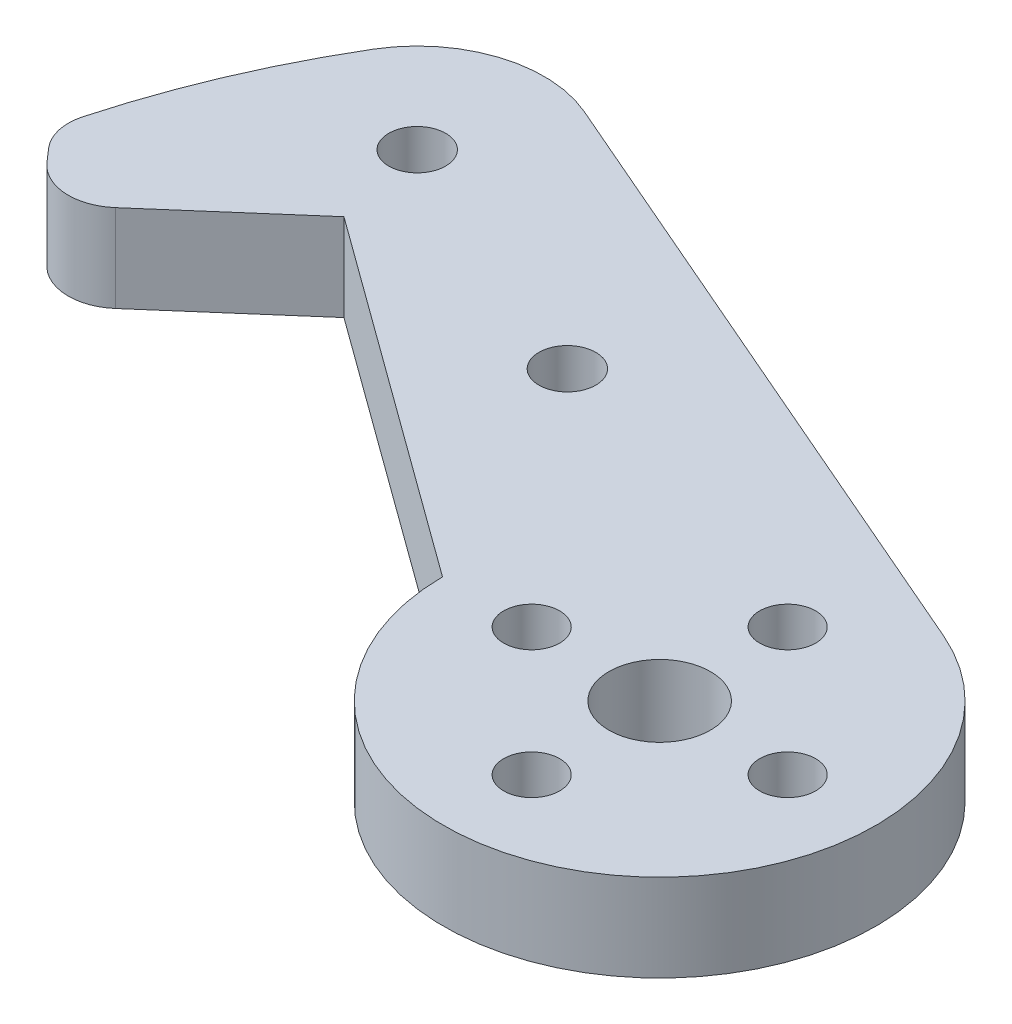
from build123d import *

# Parameters (mm, degrees)
SKETCH1_R           = 1.75
SKETCH1_R_2         = 3.175
SKETCH1_R_3         = 1.778
BOSS_EXTRUDE1_DEPTH = 5.461


with BuildPart() as part:
    # Sketch1 → Boss-Extrude1 (new body)
    with BuildSketch(Plane(origin=(0, 0, 0), x_dir=(1, 0, 0), z_dir=(0, 1, 0))):
        with BuildLine():
            Line((-36.075553112, 16.34222836), (-43.713289862, 9.687095487))
            ThreePointArc((-43.713289862, 9.687095487), (-46.071262537, 8.895051227), (-48.298660873, 10.002329828))
            Line((-48.298660873, 10.002329828), (-49.01441114, 10.823757773))
            ThreePointArc((-49.01441114, 10.823757773), (-49.677098428, 12.125807852), (-49.646194202, 13.586469955))
            ThreePointArc((-49.646194202, 13.586469955), (-47.370124011, 20.134748964), (-44.234733225, 26.317772344))
            ThreePointArc((-44.234733225, 26.317772344), (-39.855484626, 29.811728531), (-34.259632886, 29.543416329))
            Line((-34.259632886, 29.543416329), (5.363638877, 12.388760148))
            ThreePointArc((5.363638877, 12.388760148), (7.44200849, -11.263503435), (-13.499793526, -0.074664302))
            Line((-13.499793526, -0.074664302), (-36.075553112, 16.34222836))
        make_face()
        with Locations((8, 0)):
            Circle(SKETCH1_R, mode=Mode.SUBTRACT)
        with Locations((0, -8)):
            Circle(SKETCH1_R, mode=Mode.SUBTRACT)
        with Locations((-8, 0)):
            Circle(SKETCH1_R, mode=Mode.SUBTRACT)
        with Locations((0, 8)):
            Circle(SKETCH1_R, mode=Mode.SUBTRACT)
        Circle(SKETCH1_R_2, mode=Mode.SUBTRACT)
        with Locations((-20.862458922, 15.093717491)):
            Circle(SKETCH1_R_3, mode=Mode.SUBTRACT)
        with Locations((-37.413253893, 22.259284205)):
            Circle(SKETCH1_R_3, mode=Mode.SUBTRACT)
    extrude(amount=BOSS_EXTRUDE1_DEPTH)


solid = part.part
